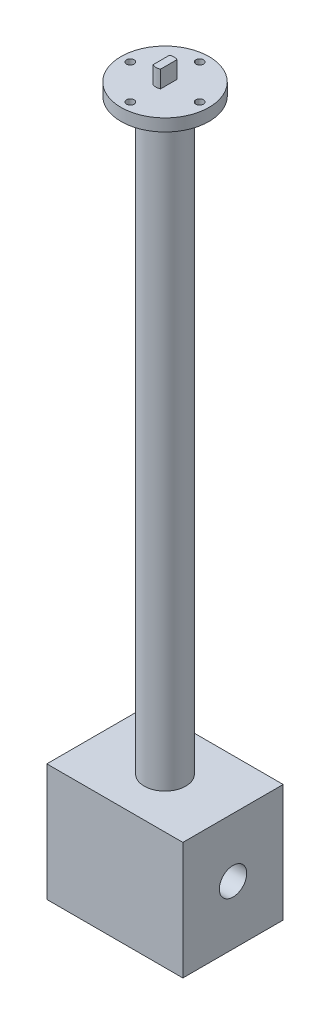
from build123d import *

# Parameters (mm, degrees)
SKETCH1_R                           = 22.86
BOSS_EXTRUDE1_DEPTH                 = 6.35
BOSS_EXTRUDE2_DEPTH                 = 8.89
SKETCH3_R                           = 10.795
BOSS_EXTRUDE3_DEPTH                 = 304.8
CHAMFER1_SIZE                       = 3.81
F_5_32_0_15625_DIAMETER_HOLE1_D     = 3.96875
F_5_32_0_15625_DIAMETER_HOLE1_DEPTH = 6.351
CIRPATTERN1_COUNT                   = 4
SKETCH7_W                           = 70.612
SKETCH7_H                           = 52.07
BOSS_EXTRUDE4_DEPTH                 = 60.96
SKETCH8_R                           = 7.112
CUT_EXTRUDE1_DEPTH                  = 71.612


with BuildPart() as part:
    # Sketch1 → Boss-Extrude1 (new body)
    with BuildSketch(Plane(origin=(0, 0, 0), x_dir=(1, 0, 0), z_dir=(0, 1, 0))):
        Circle(SKETCH1_R)
    extrude(amount=BOSS_EXTRUDE1_DEPTH)

    # Sketch2 → Boss-Extrude2 (add)
    with BuildSketch(Plane(origin=(0, 6.35, 0), x_dir=(1, 0, 0), z_dir=(0, 1, 0))):
        with BuildLine():
            Line((1.9685, -4.266803107), (1.9685, 4.266803107))
            ThreePointArc((1.9685, 4.266803107), (0, 4.699), (-1.9685, 4.266803107))
            Line((-1.9685, 4.266803107), (-1.9685, -4.266803107))
            ThreePointArc((-1.9685, -4.266803107), (0, -4.699), (1.9685, -4.266803107))
        make_face()
    extrude(amount=BOSS_EXTRUDE2_DEPTH)

    # Sketch3 → Boss-Extrude3 (add)
    with BuildSketch(Plane.XZ):
        Circle(SKETCH3_R)
    extrude(amount=BOSS_EXTRUDE3_DEPTH)

    # Chamfer1
    chamfer1_edges = [part.edges().sort_by_distance(p)[0] for p in [
        (-10.795, 0, 0),
    ]]
    chamfer(chamfer1_edges, length=CHAMFER1_SIZE)

    # 5/32 (0.15625) Diameter Hole1
    with Locations(Plane(origin=(0, 6.35, 0), x_dir=(1, 0, 0), z_dir=(0, 1, 0))):
        with Locations((0, 18)):
            f_5_32_0_15625_diameter_hole1 = Hole(F_5_32_0_15625_DIAMETER_HOLE1_D / 2, depth=F_5_32_0_15625_DIAMETER_HOLE1_DEPTH)

    # CirPattern1: 5/32 (0.15625) Diameter Hole1 ×4 about axis
    cirpattern1_axis = Axis((0, 0, 0), (0, 1, 0))
    for i in range(1, CIRPATTERN1_COUNT):
        add(f_5_32_0_15625_diameter_hole1.rotate(cirpattern1_axis, i * 360 / CIRPATTERN1_COUNT), mode=Mode.SUBTRACT)

    # Sketch7 → Boss-Extrude4 (add)
    with BuildSketch(Plane.XZ.offset(304.8)):
        Rectangle(SKETCH7_W, SKETCH7_H)
    extrude(amount=BOSS_EXTRUDE4_DEPTH)

    # Sketch8 → Cut-Extrude1 (cut, through all)
    with BuildSketch(Plane(origin=(35.306, 0, 0), x_dir=(0, 0, -1), z_dir=(1, 0, 0))):
        with Locations((0, -335.28)):
            Circle(SKETCH8_R)
    extrude(amount=-CUT_EXTRUDE1_DEPTH, mode=Mode.SUBTRACT)


solid = part.part
